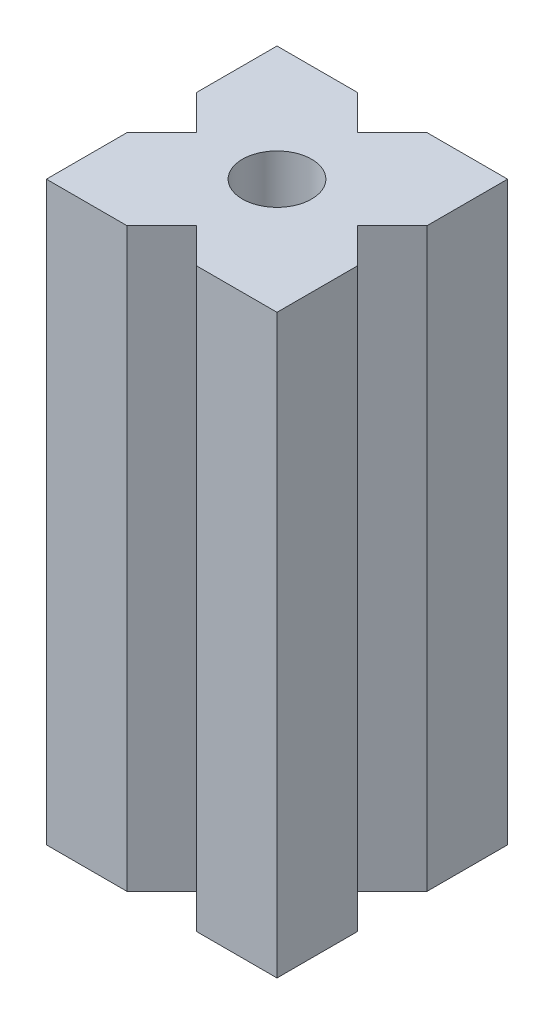
from build123d import *

# Parameters (mm, degrees)
SKIZZE1_W                       = 20
SKIZZE1_H                       = 20
AUFSATZ_LINEAR_AUSTRAGEN1_DEPTH = 25
SCHNITT_LINEAR_AUSTRAGEN1_DEPTH = 51
SKIZZE3_R                       = 3
SCHNITT_LINEAR_AUSTRAGEN2_DEPTH = 51


with BuildPart() as part:
    # Skizze1 → Aufsatz-Linear austragen1 (new body, symmetric)
    with BuildSketch(Plane(origin=(0, 0, 0), x_dir=(1, 0, 0), z_dir=(0, 1, 0))):
        Rectangle(SKIZZE1_W, SKIZZE1_H)
    extrude(amount=AUFSATZ_LINEAR_AUSTRAGEN1_DEPTH, both=True)

    # Skizze2 → Schnitt-Linear austragen1 (cut, through all)
    with BuildSketch(Plane(origin=(0, 25, 0), x_dir=(1, 0, 0), z_dir=(0, 1, 0))):
        Polygon((-3, 10), (0, 7), (3, 10), align=None)
        Polygon((10, 3), (7, 0), (10, -3), align=None)
        Polygon((-10, -3), (-10, 3), (-7, 0), align=None)
        Polygon((-3, -10), (3, -10), (0, -7), align=None)
    extrude(amount=-SCHNITT_LINEAR_AUSTRAGEN1_DEPTH, mode=Mode.SUBTRACT)

    # Skizze3 → Schnitt-Linear austragen2 (cut, through all)
    with BuildSketch(Plane(origin=(0, 25, 0), x_dir=(1, 0, 0), z_dir=(0, 1, 0))):
        Circle(SKIZZE3_R)
    extrude(amount=-SCHNITT_LINEAR_AUSTRAGEN2_DEPTH, mode=Mode.SUBTRACT)


solid = part.part
